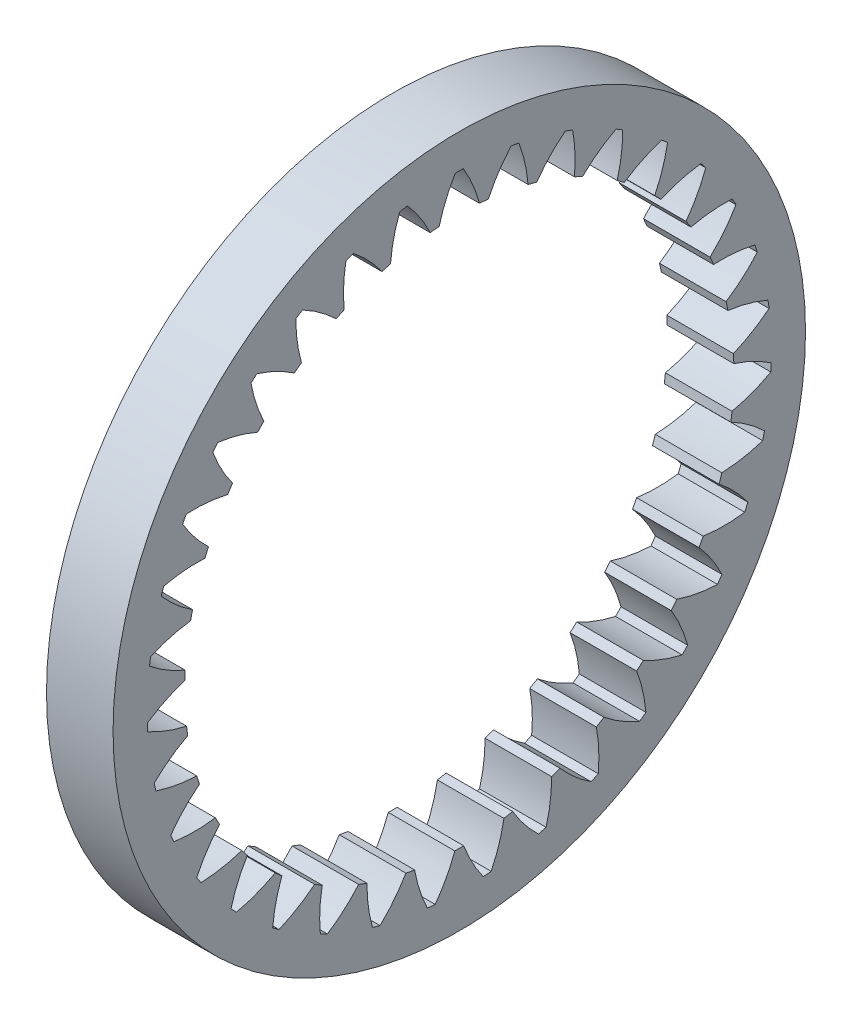
from build123d import *

# Parameters (mm, degrees)
BASPROSKE_W     = 10
BASPROSKE_H     = 10.75
TOOTHCUT_DEPTH  = 75.215901261
TEETHCUTS_COUNT = 35
TEETHCUTS_ANGLE = 349.714285714


with BuildPart() as part:
    # BasProSke → Base-Revolve (revolve)
    with BuildSketch(Plane(origin=(0, 0, 0), x_dir=(1, 0, 0), z_dir=(0, 1, 0))):
        with Locations((5, 46.625)):
            Rectangle(BASPROSKE_W, BASPROSKE_H)
    revolve(axis=Axis((-10, 0, 0), (1, 0, 0)))

    # TooCutSke → ToothCut (cut, through all)
    with BuildSketch(Plane(origin=(0, 0, 0), x_dir=(0, 0, -1), z_dir=(1, 0, 0))):
        with BuildLine():
            ThreePointArc((3.038610236, 41.112461529), (2.021011751, 44.080433709), (0.58927485, 46.872295988))
            ThreePointArc((0.58927485, 46.872295988), (0, 46.876), (-0.58927485, 46.872295988))
            ThreePointArc((-0.58927485, 46.872295988), (-2.021011751, 44.080433709), (-3.038610236, 41.112461529))
            ThreePointArc((-3.038610236, 41.112461529), (0, 41.2246), (3.038610236, 41.112461529))
        make_face()
    toothcut = extrude(amount=TOOTHCUT_DEPTH, mode=Mode.SUBTRACT)

    # TeethCuts: ToothCut ×35 about axis
    teethcuts_axis = Axis((-10, 0, 0), (1, 0, 0))
    for i in range(1, TEETHCUTS_COUNT):
        add(toothcut.rotate(teethcuts_axis, i * TEETHCUTS_ANGLE / (TEETHCUTS_COUNT - 1)), mode=Mode.SUBTRACT)


solid = part.part
